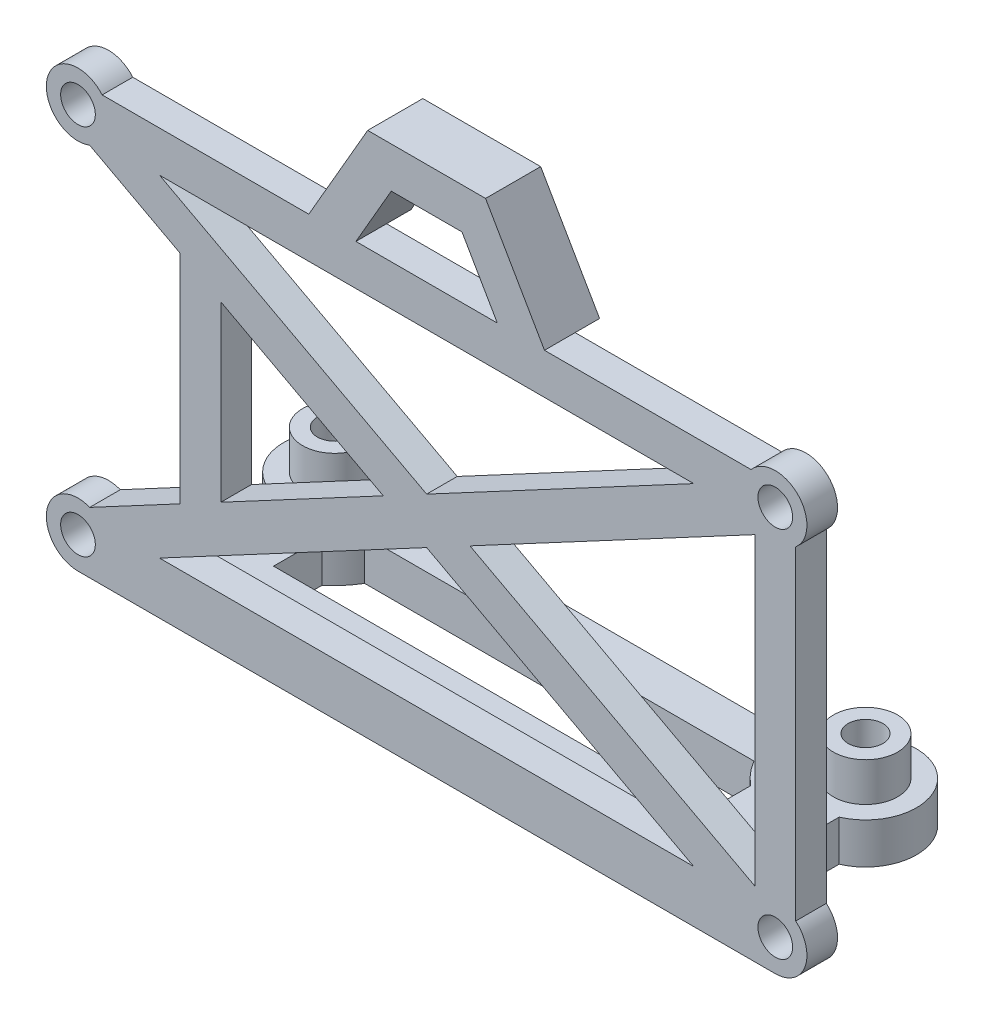
from build123d import *

# Parameters (mm, degrees)
SKETCH1_R           = 1.7
BOSS_EXTRUDE1_DEPTH = 3
SKETCH2_R           = 1.7
BOSS_EXTRUDE2_DEPTH = 4
BOSS_EXTRUDE3_START = -4
SKETCH2_3_R         = 3.15
SKETCH2_3_R_2       = 1.7
BOSS_EXTRUDE3_DEPTH = 3.8
BOSS_EXTRUDE4_DEPTH = 2.4


with BuildPart() as part:
    # Sketch1 → Boss-Extrude1 (new body)
    with BuildSketch(Plane.XY):
        with BuildLine():
            Line((-33.013012558, 15.364996561), (-24.16, 10.636565235))
            Line((-24.16, 10.636565235), (-24.16, -10.636565235))
            Line((-24.16, -10.636565235), (-33.013012558, -15.364996561))
            ThreePointArc((-33.013012558, -15.364996561), (-37.204504119, -17.661052511), (-34.16, -21.345))
            Line((-34.16, -21.345), (34.16, -21.345))
            ThreePointArc((34.16, -21.345), (37.071398801, -19.30978027), (36.16, -15.876456144))
            Line((36.16, -15.876456144), (36.16, 15.876456144))
            ThreePointArc((36.16, 15.876456144), (36.352031022, 20.437031022), (31.791456144, 20.245))
            Line((31.791456144, 20.245), (11.547005384, 20.245))
            Line((11.547005384, 20.245), (5.773502692, 30.245))
            Line((5.773502692, 30.245), (-5.773502692, 30.245))
            Line((-5.773502692, 30.245), (-11.547005384, 20.245))
            Line((-11.547005384, 20.245), (-31.791456144, 20.245))
            ThreePointArc((-31.791456144, 20.245), (-37.167216066, 18.9977626), (-33.013012558, 15.364996561))
        make_face()
        Polygon((32.16, -14.909398958), (4.24522508, 0), (32.16, 14.909398958), align=None, mode=Mode.SUBTRACT)
        Polygon((6.92820323, 20.245), (-6.92820323, 20.245), (-3.464101615, 26.245), (3.464101615, 26.245), align=None, mode=Mode.SUBTRACT)
        Polygon((-4.24522508, 0), (-20.16, -8.500148373), (-20.16, 8.500148373), align=None, mode=Mode.SUBTRACT)
        Polygon((26.170187362, -16.245), (-26.170187362, -16.245), (0, -2.267392611), align=None, mode=Mode.SUBTRACT)
        Polygon((0, 2.267392611), (-26.170187362, 16.245), (26.170187362, 16.245), align=None, mode=Mode.SUBTRACT)
        with Locations((-34.16, 18.245)):
            Circle(SKETCH1_R, mode=Mode.SUBTRACT)
        with Locations((-34.16, -18.245)):
            Circle(SKETCH1_R, mode=Mode.SUBTRACT)
        with Locations((34.16, -18.245)):
            Circle(SKETCH1_R, mode=Mode.SUBTRACT)
        with Locations((34.16, 18.245)):
            Circle(SKETCH1_R, mode=Mode.SUBTRACT)
    extrude(amount=-BOSS_EXTRUDE1_DEPTH)

    # Sketch2 → Boss-Extrude2 (add)
    with BuildSketch(Plane.XZ.offset(21.345)):
        with BuildLine():
            Line((-28, -3), (-28, -12.417424305))
            ThreePointArc((-28, -12.417424305), (-28.738612788, -21.183300133), (-21, -17))
            Line((-21, -17), (21, -17))
            ThreePointArc((21, -17), (28.738612788, -21.183300133), (28, -12.417424305))
            Line((28, -12.417424305), (28, -3))
            Line((28, -3), (-28, -3))
        make_face()
        with BuildLine():
            Line((19.07179677, -13), (-19.07179677, -13))
            ThreePointArc((-19.07179677, -13), (-19.931185282, -11.787564109), (-21, -10.755002002))
            Line((-21, -10.755002002), (-21, -6))
            Line((-21, -6), (21, -6))
            Line((21, -6), (21, -10.755002002))
            ThreePointArc((21, -10.755002002), (19.931185282, -11.787564109), (19.07179677, -13))
        make_face(mode=Mode.SUBTRACT)
        with Locations((-26, -17)):
            Circle(SKETCH2_R, mode=Mode.SUBTRACT)
        with Locations((26, -17)):
            Circle(SKETCH2_R, mode=Mode.SUBTRACT)
    extrude(amount=-BOSS_EXTRUDE2_DEPTH)

    # Sketch2_3 → Boss-Extrude3 (add)
    with BuildSketch(Plane.XZ.offset(21.345).offset(BOSS_EXTRUDE3_START)):
        with Locations((-26, -17)):
            Circle(SKETCH2_3_R)
        with Locations((-26, -17)):
            Circle(SKETCH2_3_R_2, mode=Mode.SUBTRACT)
        with Locations((26, -17)):
            Circle(SKETCH2_3_R)
        with Locations((26, -17)):
            Circle(SKETCH2_3_R_2, mode=Mode.SUBTRACT)
    extrude(amount=-BOSS_EXTRUDE3_DEPTH)

    # Sketch3 → Boss-Extrude4 (add)
    with BuildSketch(Plane(origin=(0, 0, -3), x_dir=(-1, 0, 0), z_dir=(0, 0, -1))):
        Polygon((-3.464101615, 26.245), (3.464101615, 26.245), (6.92820323, 20.245), (11.547005384, 20.245), (5.773502692, 30.245), (-5.773502692, 30.245), (-11.547005384, 20.245), (-6.92820323, 20.245), align=None)
    extrude(amount=BOSS_EXTRUDE4_DEPTH)


solid = part.part
